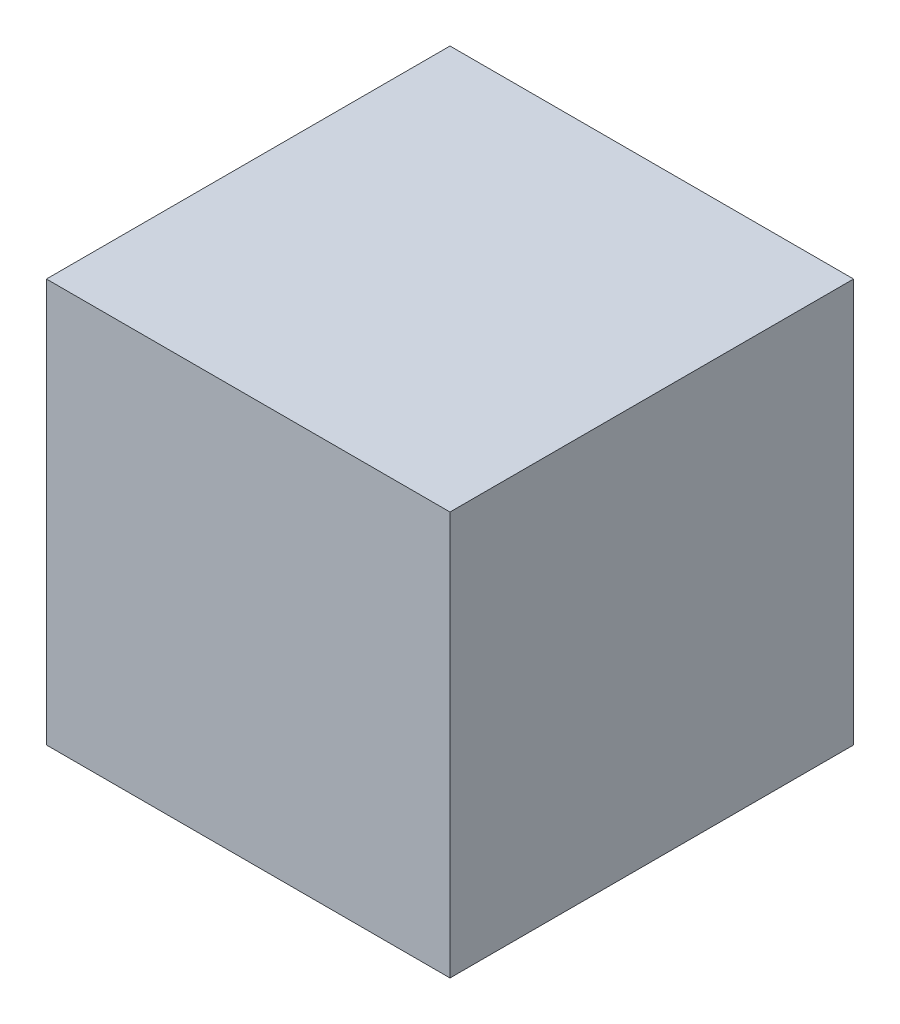
from build123d import *

# Parameters (mm, degrees)
BOSS_EXTRU_1_DEPTH      = 25
BOSS_EXTRU_1_DEPTH_BACK = 25
ESQUISSE1_W             = 50
ESQUISSE1_H             = 50


with BuildPart() as part:
    # Esquisse1 → Boss.-Extru.1 (new, two sides: drawn at the far end of the back side and taken through both)
    with BuildSketch(Plane.XY.offset(-BOSS_EXTRU_1_DEPTH_BACK)):
        Rectangle(ESQUISSE1_W, ESQUISSE1_H)
    extrude(amount=BOSS_EXTRU_1_DEPTH + BOSS_EXTRU_1_DEPTH_BACK)


solid = part.part
